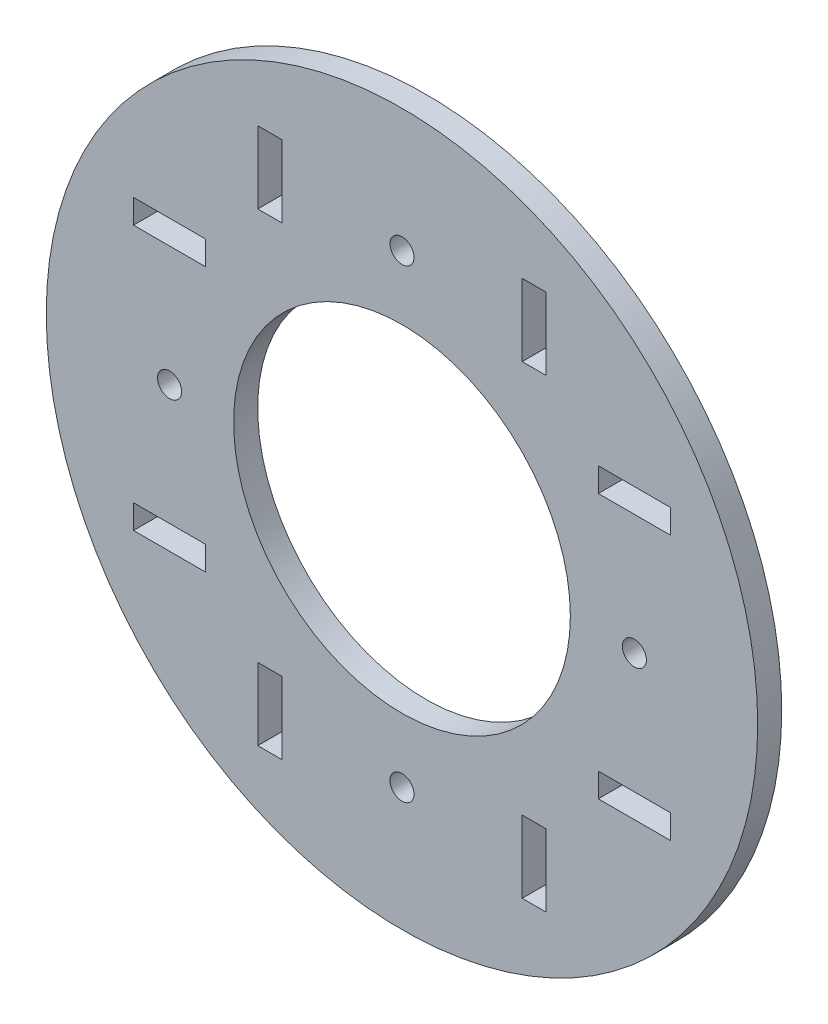
from build123d import *

# Parameters (mm, degrees)
SKETCH2_R           = 46.99
SKETCH2_R_2         = 1.5875
SKETCH2_R_3         = 22.240762899
BOSS_EXTRUDE1_DEPTH = 3.175


with BuildPart() as part:
    # Sketch2 → Boss-Extrude1 (new body)
    with BuildSketch(Plane.XY):
        Circle(SKETCH2_R)
        with Locations((0, -30.69717)):
            Circle(SKETCH2_R_2, mode=Mode.SUBTRACT)
        with Locations((0, 30.69717)):
            Circle(SKETCH2_R_2, mode=Mode.SUBTRACT)
        with Locations((30.69717, 0)):
            Circle(SKETCH2_R_2, mode=Mode.SUBTRACT)
        with Locations((-30.69717, 0)):
            Circle(SKETCH2_R_2, mode=Mode.SUBTRACT)
        Circle(SKETCH2_R_3, mode=Mode.SUBTRACT)
        Polygon((-19.05, -35.45967), (-15.875, -35.45967), (-15.875, -25.93467), (-19.05, -25.93467), (-19.05, -32.28467), align=None, mode=Mode.SUBTRACT)
        Polygon((-19.05, 32.28467), (-19.05, 35.45967), (-15.875, 35.45967), (-15.875, 25.93467), (-19.05, 25.93467), align=None, mode=Mode.SUBTRACT)
        Polygon((19.05, 35.45967), (15.875, 35.45967), (15.875, 25.93467), (19.05, 25.93467), (19.05, 32.28467), align=None, mode=Mode.SUBTRACT)
        Polygon((19.05, -32.28467), (19.05, -25.93467), (15.875, -25.93467), (15.875, -35.45967), (19.05, -35.45967), align=None, mode=Mode.SUBTRACT)
        Polygon((-35.45967, -19.05), (-35.45967, -15.875), (-25.93467, -15.875), (-25.93467, -19.05), (-32.28467, -19.05), align=None, mode=Mode.SUBTRACT)
        Polygon((-32.28467, 19.05), (-35.45967, 19.05), (-35.45967, 15.875), (-25.93467, 15.875), (-25.93467, 19.05), align=None, mode=Mode.SUBTRACT)
        Polygon((35.45967, 19.05), (35.45967, 15.875), (25.93467, 15.875), (25.93467, 19.05), (32.28467, 19.05), align=None, mode=Mode.SUBTRACT)
        Polygon((32.28467, -19.05), (35.45967, -19.05), (35.45967, -15.875), (25.93467, -15.875), (25.93467, -19.05), align=None, mode=Mode.SUBTRACT)
    extrude(amount=BOSS_EXTRUDE1_DEPTH)


solid = part.part
